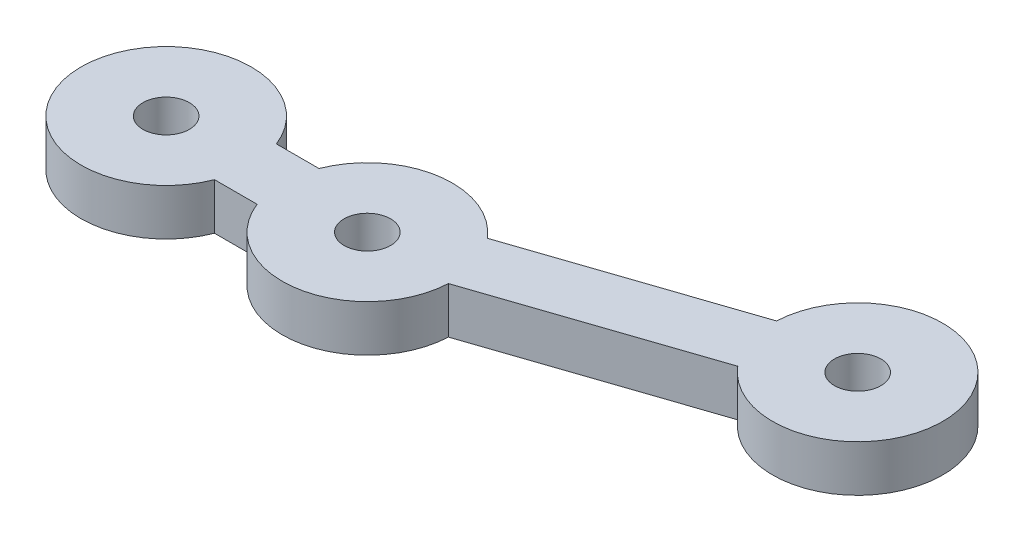
from build123d import *

# Parameters (mm, degrees)
SKETCH1_R           = 1.5
BOSS_EXTRUDE1_DEPTH = 3


with BuildPart() as part:
    # Sketch1 → Boss-Extrude1 (new body)
    with BuildSketch(Plane(origin=(0, 0, 0), x_dir=(1, 0, 0), z_dir=(0, 1, 0))):
        with BuildLine():
            ThreePointArc((5.123475383, 2), (-5.5, 0), (5.123475383, -2))
            Line((5.123475383, -2), (7.876524617, -2))
            ThreePointArc((7.876524617, -2), (13.891801362, -5.42721755), (18.494070457, -0.255322963))
            Line((18.494070457, -0.255322963), (32.471368108, 4.465652792))
            ThreePointArc((32.471368108, 4.465652792), (41.896235049, 9.76), (31.191368108, 8.255322963))
            Line((31.191368108, 8.255322963), (17.214070457, 3.534347208))
            ThreePointArc((17.214070457, 3.534347208), (12.108198638, 5.42721755), (7.876524617, 2))
            Line((7.876524617, 2), (5.123475383, 2))
        make_face()
        Circle(SKETCH1_R, mode=Mode.SUBTRACT)
        with Locations((13, 0)):
            Circle(SKETCH1_R, mode=Mode.SUBTRACT)
        with Locations((36.685438565, 8)):
            Circle(SKETCH1_R, mode=Mode.SUBTRACT)
    extrude(amount=BOSS_EXTRUDE1_DEPTH)


solid = part.part
